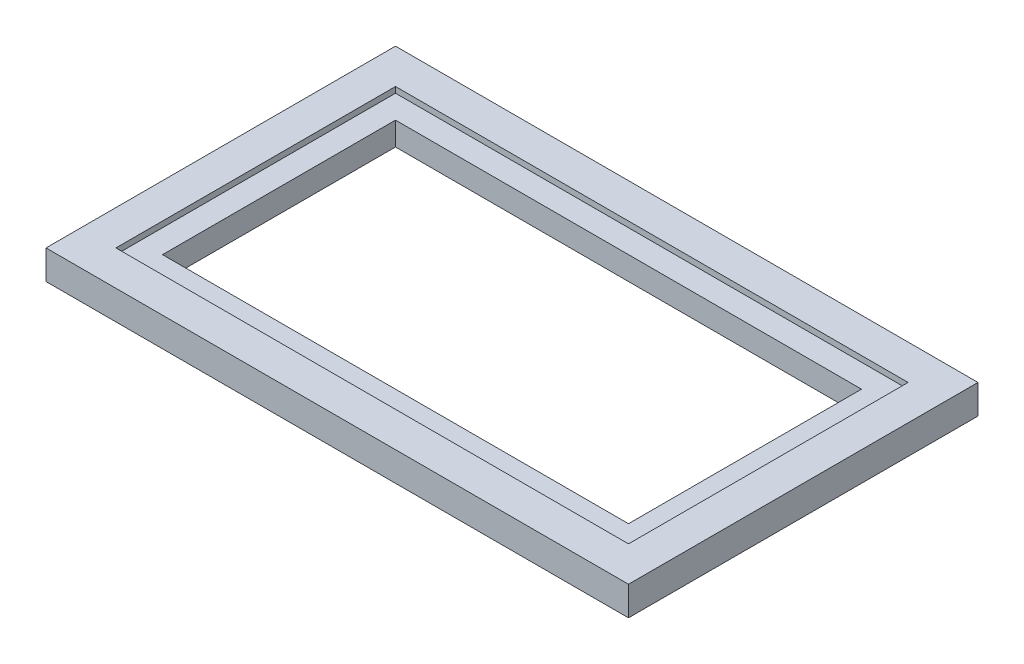
from build123d import *

# Parameters (mm, degrees)
SKETCH1_W           = 1000
SKETCH1_H           = 600
BOSS_EXTRUDE1_DEPTH = 50
SKETCH2_W           = 800
SKETCH2_H           = 400
CUT_EXTRUDE1_DEPTH  = 51
SKETCH3_W           = 880
SKETCH3_H           = 480
CUT_EXTRUDE2_DEPTH  = 10


with BuildPart() as part:
    # Sketch1 → Boss-Extrude1 (new body)
    with BuildSketch(Plane(origin=(0, 0, 0), x_dir=(1, 0, 0), z_dir=(0, 1, 0))):
        Rectangle(SKETCH1_W, SKETCH1_H)
    extrude(amount=BOSS_EXTRUDE1_DEPTH)

    # Sketch2 → Cut-Extrude1 (cut, through all)
    with BuildSketch(Plane(origin=(0, 50, 0), x_dir=(1, 0, 0), z_dir=(0, 1, 0))):
        Rectangle(SKETCH2_W, SKETCH2_H)
    extrude(amount=-CUT_EXTRUDE1_DEPTH, mode=Mode.SUBTRACT)

    # Sketch3 → Cut-Extrude2 (cut)
    with BuildSketch(Plane(origin=(0, 50, 0), x_dir=(1, 0, 0), z_dir=(0, 1, 0))):
        Rectangle(SKETCH3_W, SKETCH3_H)
    extrude(amount=-CUT_EXTRUDE2_DEPTH, mode=Mode.SUBTRACT)


solid = part.part
